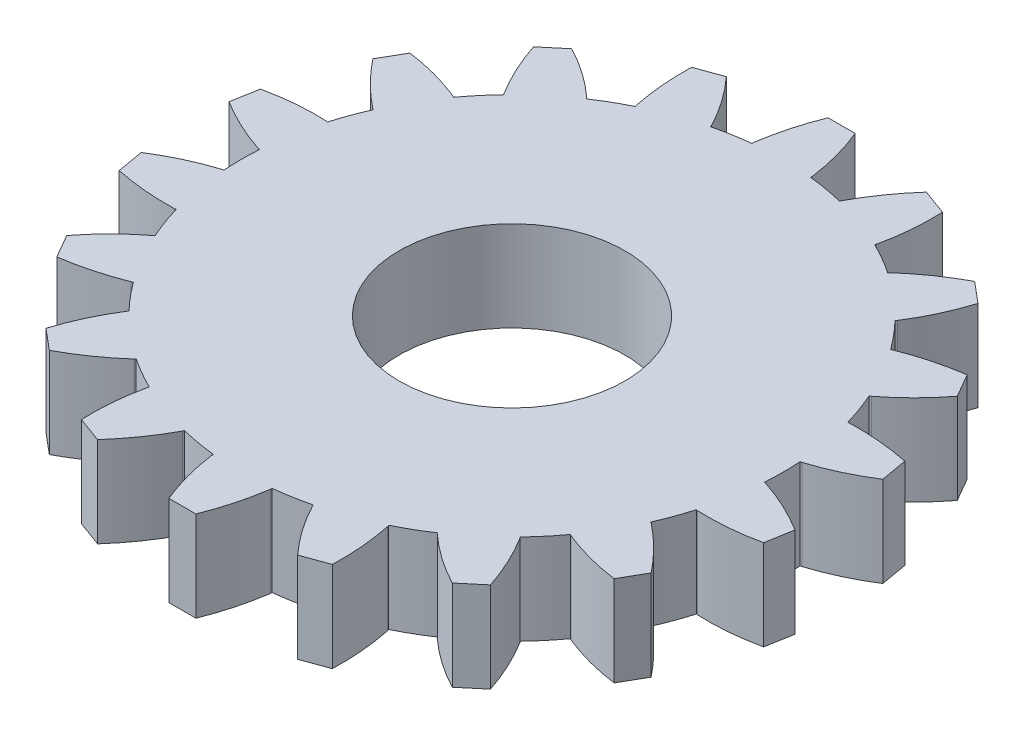
from build123d import *

# Parameters (mm, degrees)
SKETCH1_R                = 6
BOSS_EXTRUDE1_DEPTH      = 2
SKETCH2_R                = 1.25
CUT_EXTRUDE1_DEPTH       = 3
CUT_EXTRUDE1_DEPTH_BACK  = 4
SKETCH3_R                = 2
SKETCH3_R_2              = 0.75
BOSS_EXTRUDE2_DEPTH      = 0.2
BOSS_EXTRUDE2_DEPTH_BACK = 2.2
BOSS_EXTRUDE3_DEPTH      = 2
CIRPATTERN1_COUNT        = 18
SKETCH5_R                = 2.5
CUT_EXTRUDE2_DEPTH       = 3
CUT_EXTRUDE2_DEPTH_BACK  = 5


with BuildPart() as part:
    # Sketch1 → Boss-Extrude1 (new body)
    with BuildSketch(Plane(origin=(0, 0, 0), x_dir=(1, 0, 0), z_dir=(0, 1, 0))):
        Circle(SKETCH1_R)
    extrude(amount=BOSS_EXTRUDE1_DEPTH)

    # Sketch2 → Cut-Extrude1 (cut, two sides)
    with BuildSketch(Plane(origin=(0, 2, 0), x_dir=(1, 0, 0), z_dir=(0, 1, 0))) as cut_extrude1_sk:
        Circle(SKETCH2_R)
    extrude(amount=CUT_EXTRUDE1_DEPTH, mode=Mode.SUBTRACT)
    extrude(cut_extrude1_sk.sketch, amount=-CUT_EXTRUDE1_DEPTH_BACK, mode=Mode.SUBTRACT)

    # Sketch3 → Boss-Extrude2 (add, two sides)
    with BuildSketch(Plane(origin=(0, 2, 0), x_dir=(1, 0, 0), z_dir=(0, 1, 0))) as boss_extrude2_sk:
        Circle(SKETCH3_R)
        Circle(SKETCH3_R_2, mode=Mode.SUBTRACT)
    extrude(amount=BOSS_EXTRUDE2_DEPTH)
    extrude(boss_extrude2_sk.sketch, amount=-BOSS_EXTRUDE2_DEPTH_BACK)

    # Sketch4 → Boss-Extrude3 (add)
    with BuildSketch(Plane(origin=(0, 2, 0), x_dir=(1, 0, 0), z_dir=(0, 1, 0))):
        with BuildLine():
            Line((-0.3, 7.3), (0.3, 7.3))
            ThreePointArc((0.3, 7.3), (0.517384179, 6.661411125), (0.65, 6))
            Line((0.65, 6), (0.65, 5.964687754))
            ThreePointArc((0.65, 5.964687754), (0, 6), (-0.65, 5.964687754))
            Line((-0.65, 5.964687754), (-0.65, 6))
            ThreePointArc((-0.65, 6), (-0.512944228, 6.660215754), (-0.3, 7.3))
        make_face()
    boss_extrude3 = extrude(amount=-BOSS_EXTRUDE3_DEPTH)

    # CirPattern1: Boss-Extrude3 ×18 about axis
    cirpattern1_axis = Axis((0, 0, 0), (0, 1, 0))
    for i in range(1, CIRPATTERN1_COUNT):
        add(boss_extrude3.rotate(cirpattern1_axis, i * 360 / CIRPATTERN1_COUNT))

    # Sketch5 → Cut-Extrude2 (cut, two sides)
    with BuildSketch(Plane(origin=(0, 2, 0), x_dir=(1, 0, 0), z_dir=(0, 1, 0))) as cut_extrude2_sk:
        Circle(SKETCH5_R)
    extrude(amount=CUT_EXTRUDE2_DEPTH, mode=Mode.SUBTRACT)
    extrude(cut_extrude2_sk.sketch, amount=-CUT_EXTRUDE2_DEPTH_BACK, mode=Mode.SUBTRACT)


solid = part.part
